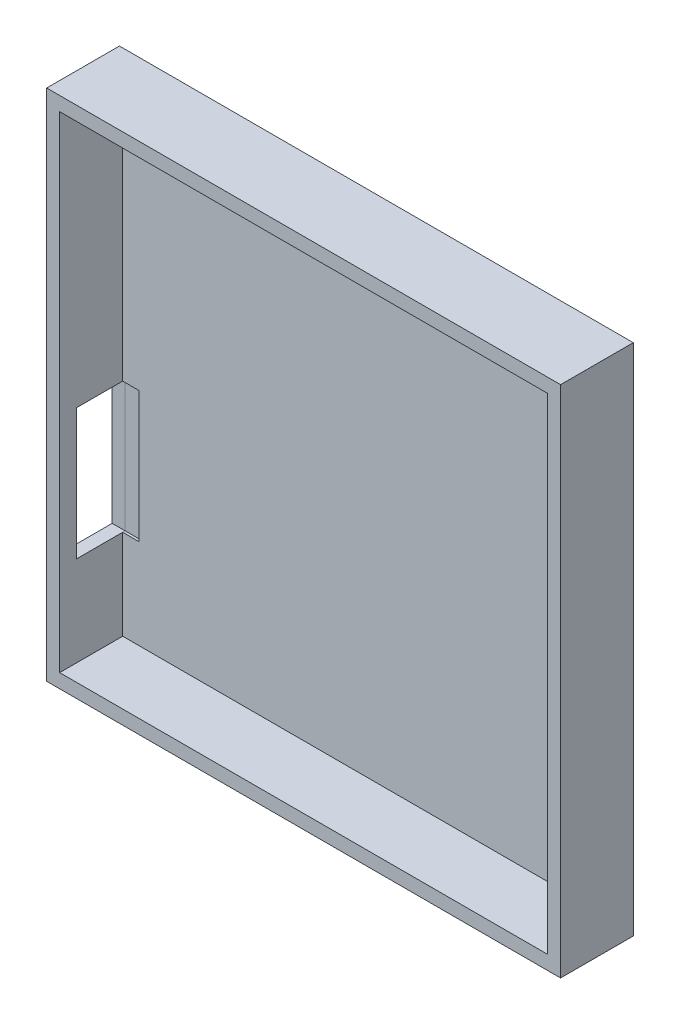
from build123d import *

# Parameters (mm, degrees)
SKETCH2_W           = 106
SKETCH2_H           = 106
SKETCH2_W_2         = 100.659036826
SKETCH2_H_2         = 100.220116606
BOSS_EXTRUDE2_DEPTH = 15
SKETCH2_5_W         = 100.659036826
SKETCH2_5_H         = 100.220116606
BOSS_EXTRUDE5_DEPTH = 2
SKETCH6_W           = 10
SKETCH6_H           = 27
CUT_EXTRUDE1_DEPTH  = 6


with BuildPart() as part:
    # Sketch2 → Boss-Extrude2 (new body)
    with BuildSketch(Plane.XY):
        with Locations((151.0037, -93.75)):
            Rectangle(SKETCH2_W, SKETCH2_H)
        with Locations((151.0037, -93.75)):
            Rectangle(SKETCH2_W_2, SKETCH2_H_2, mode=Mode.SUBTRACT)
    extrude(amount=BOSS_EXTRUDE2_DEPTH)


with BuildPart() as body_2:
    # Sketch2_5 → Boss-Extrude5 (new body)
    with BuildSketch(Plane.XY):
        with Locations((151.0037, -93.75)):
            Rectangle(SKETCH2_5_W, SKETCH2_5_H)
    extrude(amount=BOSS_EXTRUDE5_DEPTH)


with BuildPart() as cut_extrude1_tool:
    # Sketch6 → Cut-Extrude1 (new body)
    with BuildSketch(Plane.ZY.offset(-98.0037)):
        with Locations((6.5, -111.779102378)):
            Rectangle(SKETCH6_W, SKETCH6_H)
    extrude(amount=-CUT_EXTRUDE1_DEPTH)


with BuildPart() as part_1:
    add(part.part)

    # Cut-Extrude1: cut by cut_extrude1_tool
    add(cut_extrude1_tool.part, mode=Mode.SUBTRACT)


with BuildPart() as body_2_1:
    add(body_2.part)

    # Cut-Extrude1: cut by cut_extrude1_tool
    add(cut_extrude1_tool.part, mode=Mode.SUBTRACT)


solid = Compound([part_1.part, body_2_1.part])
